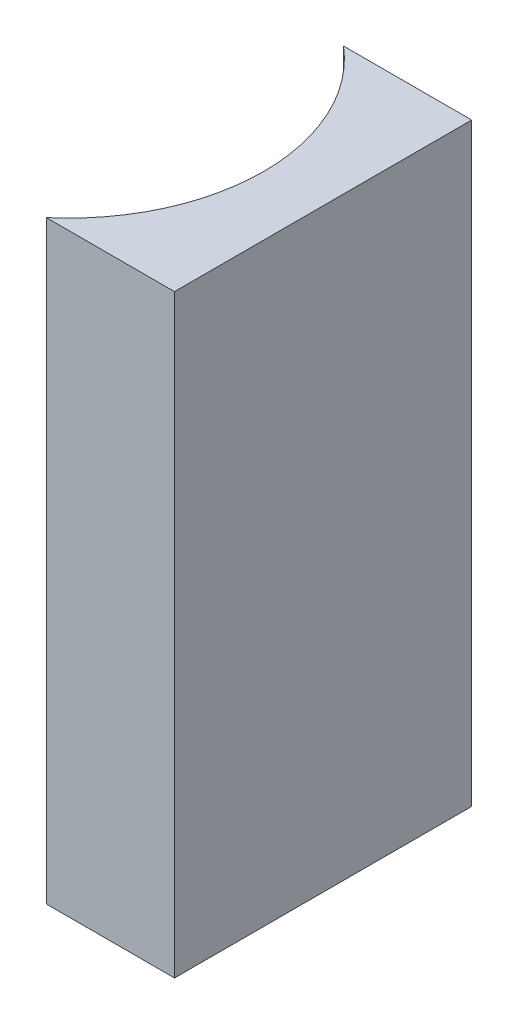
from build123d import *

# Parameters (mm, degrees)
EXTRUDE_1_DEPTH = 20


with BuildPart() as part:
    # 草图1 → 凸台-拉伸1 (new body)
    with BuildSketch(Plane(origin=(0, 0, 0), x_dir=(1, 0, 0), z_dir=(0, 1, 0))):
        with BuildLine():
            Line((0, 0), (0, -10))
            Line((0, -10), (-4.313401361, -10))
            ThreePointArc((-4.313401361, -10), (-2, -5), (-4.313401361, 0))
            Line((-4.313401361, 0), (0, 0))
        make_face()
    extrude(amount=EXTRUDE_1_DEPTH)


solid = part.part
